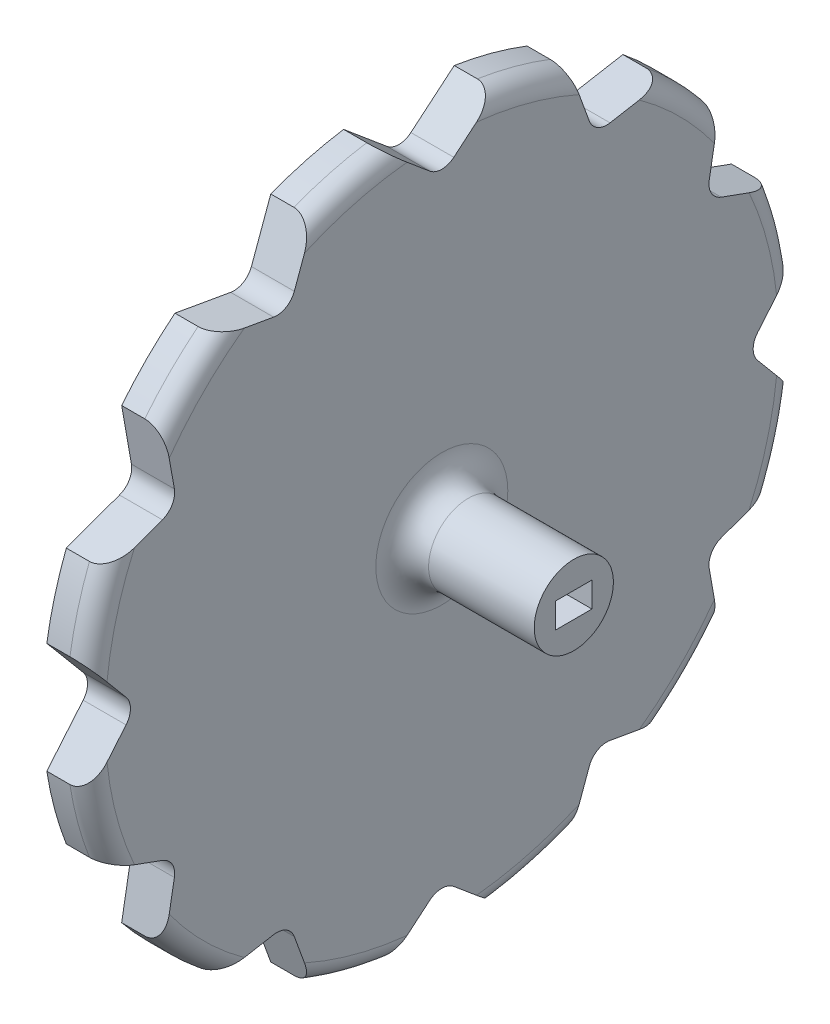
from build123d import *

# Parameters (mm, degrees)
BOSS_EXTRUDE1_DEPTH = 6.5
SKETCH2_R           = 6
BOSS_EXTRUDE2_DEPTH = 20
FILLET1_R           = 3
SKETCH3_W           = 5.5
SKETCH3_H           = 3.81
CUT_EXTRUDE1_DEPTH  = 27.5000001
FILLET2_R           = 4


with BuildPart() as part:
    # Sketch1 → Boss-Extrude1 (new body)
    with BuildSketch(Plane(origin=(0, 0, 0), x_dir=(0, 0, -1), z_dir=(1, 0, 0))):
        with BuildLine():
            Line((1.815874997, 47.835924448), (8.381939498, 53.345506749))
            ThreePointArc((8.381939498, 53.345506749), (13.976228436, 52.15999462), (19.413780836, 50.389533771))
            Line((19.413780836, 50.389533771), (22.345368346, 42.335063284))
            ThreePointArc((22.345368346, 42.335063284), (23.5875, 40.854748424), (25.490556102, 40.519188287))
            Line((25.490556102, 40.519188287), (33.931725912, 42.007594273))
            ThreePointArc((33.931725912, 42.007594273), (38.183766184, 38.183766184), (42.007594273, 33.931725912))
            Line((42.007594273, 33.931725912), (40.519188287, 25.490556102))
            ThreePointArc((40.519188287, 25.490556102), (40.854748424, 23.5875), (42.335063284, 22.345368346))
            Line((42.335063284, 22.345368346), (50.389533771, 19.413780836))
            ThreePointArc((50.389533771, 19.413780836), (52.15999462, 13.976228436), (53.345506749, 8.381939498))
            Line((53.345506749, 8.381939498), (47.835924448, 1.815874997))
            ThreePointArc((47.835924448, 1.815874997), (47.175, 0), (47.835924448, -1.815874997))
            Line((47.835924448, -1.815874997), (53.345506749, -8.381939498))
            ThreePointArc((53.345506749, -8.381939498), (52.15999462, -13.976228436), (50.389533771, -19.413780836))
            Line((50.389533771, -19.413780836), (42.335063284, -22.345368346))
            ThreePointArc((42.335063284, -22.345368346), (40.854748424, -23.5875), (40.519188287, -25.490556102))
            Line((40.519188287, -25.490556102), (42.007594273, -33.931725912))
            ThreePointArc((42.007594273, -33.931725912), (38.183766184, -38.183766184), (33.931725912, -42.007594273))
            Line((33.931725912, -42.007594273), (25.490556102, -40.519188287))
            ThreePointArc((25.490556102, -40.519188287), (23.5875, -40.854748424), (22.345368346, -42.335063284))
            Line((22.345368346, -42.335063284), (19.413780836, -50.389533771))
            ThreePointArc((19.413780836, -50.389533771), (13.976228436, -52.15999462), (8.381939498, -53.345506749))
            Line((8.381939498, -53.345506749), (1.815874997, -47.835924448))
            ThreePointArc((1.815874997, -47.835924448), (0, -47.175), (-1.815874997, -47.835924448))
            Line((-1.815874997, -47.835924448), (-8.381939498, -53.345506749))
            ThreePointArc((-8.381939498, -53.345506749), (-13.976228436, -52.15999462), (-19.413780836, -50.389533771))
            Line((-19.413780836, -50.389533771), (-22.345368346, -42.335063284))
            ThreePointArc((-22.345368346, -42.335063284), (-23.5875, -40.854748424), (-25.490556102, -40.519188287))
            Line((-25.490556102, -40.519188287), (-33.931725912, -42.007594273))
            ThreePointArc((-33.931725912, -42.007594273), (-38.183766184, -38.183766184), (-42.007594273, -33.931725912))
            Line((-42.007594273, -33.931725912), (-40.519188287, -25.490556102))
            ThreePointArc((-40.519188287, -25.490556102), (-40.854748424, -23.5875), (-42.335063284, -22.345368346))
            Line((-42.335063284, -22.345368346), (-50.389533771, -19.413780836))
            ThreePointArc((-50.389533771, -19.413780836), (-52.15999462, -13.976228436), (-53.345506749, -8.381939498))
            Line((-53.345506749, -8.381939498), (-47.835924448, -1.815874997))
            ThreePointArc((-47.835924448, -1.815874997), (-47.175, 0), (-47.835924448, 1.815874997))
            Line((-47.835924448, 1.815874997), (-53.345506749, 8.381939498))
            ThreePointArc((-53.345506749, 8.381939498), (-52.15999462, 13.976228436), (-50.389533771, 19.413780836))
            Line((-50.389533771, 19.413780836), (-42.335063284, 22.345368346))
            ThreePointArc((-42.335063284, 22.345368346), (-40.854748424, 23.5875), (-40.519188287, 25.490556102))
            Line((-40.519188287, 25.490556102), (-42.007594273, 33.931725912))
            ThreePointArc((-42.007594273, 33.931725912), (-38.183766184, 38.183766184), (-33.931725912, 42.007594273))
            Line((-33.931725912, 42.007594273), (-25.490556102, 40.519188287))
            ThreePointArc((-25.490556102, 40.519188287), (-23.5875, 40.854748424), (-22.345368346, 42.335063284))
            Line((-22.345368346, 42.335063284), (-19.413780836, 50.389533771))
            ThreePointArc((-19.413780836, 50.389533771), (-13.976228436, 52.15999462), (-8.381939498, 53.345506749))
            Line((-8.381939498, 53.345506749), (-1.815874997, 47.835924448))
            ThreePointArc((-1.815874997, 47.835924448), (0, 47.175), (1.815874997, 47.835924448))
        make_face()
    extrude(amount=BOSS_EXTRUDE1_DEPTH)

    # Sketch2 → Boss-Extrude2 (add)
    with BuildSketch(Plane(origin=(6.5, 0, 0), x_dir=(0, 0, -1), z_dir=(1, 0, 0))):
        Circle(SKETCH2_R)
    extrude(amount=BOSS_EXTRUDE2_DEPTH)

    # Fillet1
    fillet1_edges = [part.edges().sort_by_distance(p)[0] for p in [
        (6.5, -52.15999462, 13.976228436),
        (6.5, -52.15999462, -13.976228436),
        (6.5, 52.15999462, -13.976228436),
        (6.5, -38.183766184, -38.183766184),
        (6.5, -13.976228436, -52.15999462),
        (6.5, 13.976228436, -52.15999462),
        (6.5, 38.183766184, -38.183766184),
        (6.5, 52.15999462, 13.976228436),
        (6.5, 38.183766184, 38.183766184),
        (6.5, 13.976228436, 52.15999462),
        (6.5, -13.976228436, 52.15999462),
        (6.5, -38.183766184, 38.183766184),
    ]]
    fillet(fillet1_edges, radius=FILLET1_R)

    # Sketch3 → Cut-Extrude1 (cut, through all)
    with BuildSketch(Plane(origin=(26.5, 0, 0), x_dir=(0, 0, -1), z_dir=(1, 0, 0))):
        Rectangle(SKETCH3_W, SKETCH3_H)
    extrude(amount=-CUT_EXTRUDE1_DEPTH, mode=Mode.SUBTRACT)

    # Fillet2
    fillet2_edges = [part.edges().sort_by_distance(p)[0] for p in [
        (6.5, 0, 6),
    ]]
    fillet(fillet2_edges, radius=FILLET2_R)


solid = part.part
